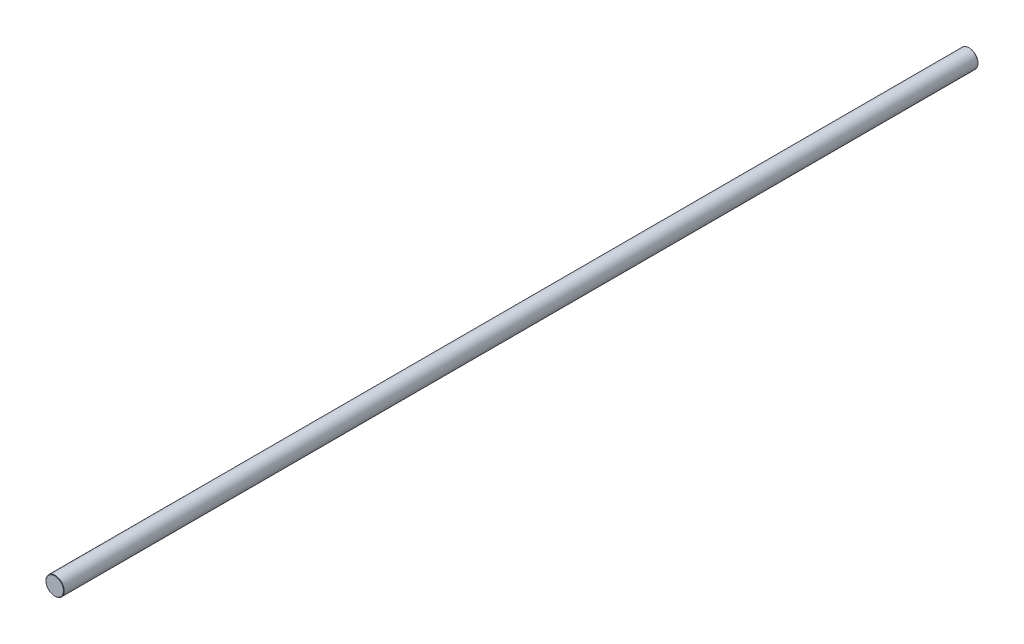
from build123d import *

# Parameters (mm, degrees)
SKETCH1_R           = 12.7
BOSS_EXTRUDE1_DEPTH = 638
CHAMFER1_SIZE       = 0.5


with BuildPart() as part:
    # Sketch1 → Boss-Extrude1 (new body, symmetric)
    with BuildSketch(Plane.XY):
        Circle(SKETCH1_R)
    extrude(amount=BOSS_EXTRUDE1_DEPTH, both=True)

    # Chamfer1
    chamfer1_edges = [part.edges().sort_by_distance(p)[0] for p in [
        (-12.7, 0, -638),
        (-12.7, 0, 638),
    ]]
    chamfer(chamfer1_edges, length=CHAMFER1_SIZE)


solid = part.part
